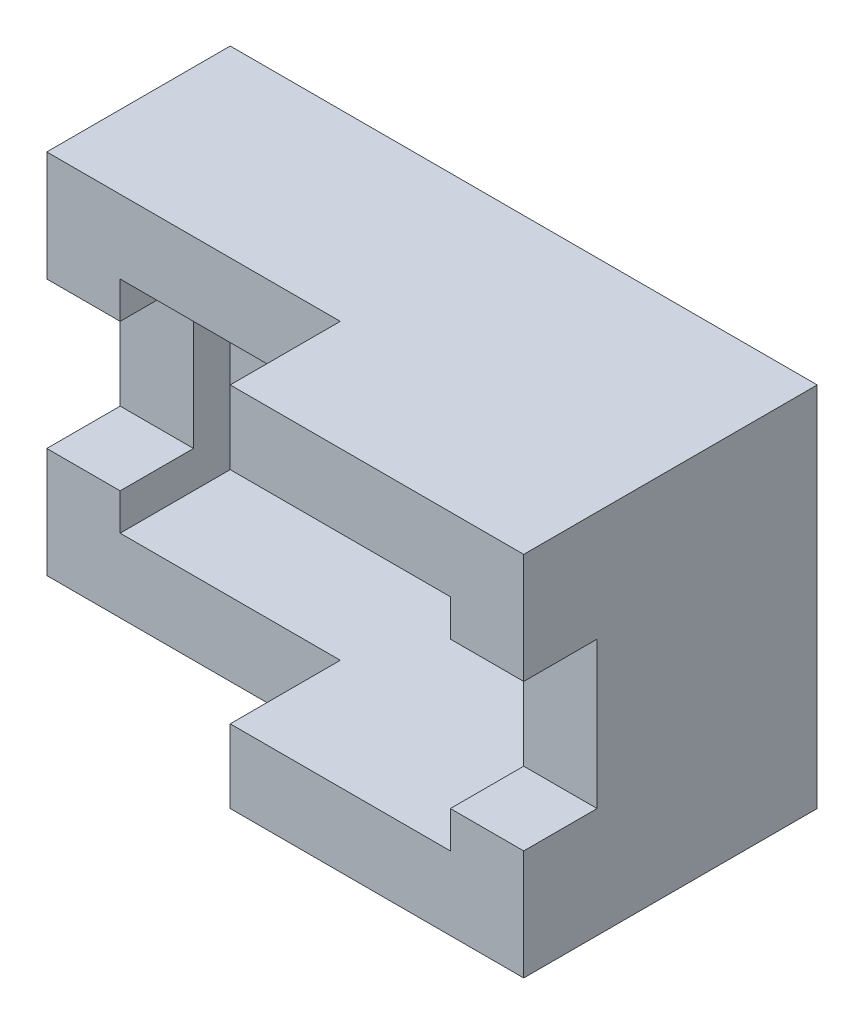
from build123d import *

# Parameters (mm, degrees)
SKETCH1_W           = 160
SKETCH1_H           = 100
BOSS_EXTRUDE1_DEPTH = 50
SKETCH2_W           = 20
SKETCH2_H           = 40
CUT_EXTRUDE1_DEPTH  = 20
SKETCH3_W           = 30
SKETCH3_H           = 20
CUT_EXTRUDE2_DEPTH  = 20
SKETCH4_W           = 120
SKETCH4_H           = 60
CUT_EXTRUDE3_DEPTH  = 30
BOSS_EXTRUDE2_DEPTH = 30
SKETCH8_W           = 30
SKETCH8_H           = 40
BOSS_EXTRUDE3_DEPTH = 20


with BuildPart() as part:
    # Sketch1 → Boss-Extrude1 (new body)
    with BuildSketch(Plane.XY):
        with Locations((80, 50)):
            Rectangle(SKETCH1_W, SKETCH1_H)
    extrude(amount=BOSS_EXTRUDE1_DEPTH)

    # Sketch2 → Cut-Extrude1 (cut)
    with BuildSketch(Plane.XY.offset(50)):
        with Locations((10, 50)):
            Rectangle(SKETCH2_W, SKETCH2_H)
        with Locations((150, 50)):
            Rectangle(SKETCH2_W, SKETCH2_H)
    extrude(amount=-CUT_EXTRUDE1_DEPTH, mode=Mode.SUBTRACT)

    # Sketch3 → Cut-Extrude2 (cut)
    with BuildSketch(Plane(origin=(0, 0, 0), x_dir=(-1, 0, 0), z_dir=(0, 0, -1))):
        with Locations((-55, 50)):
            Rectangle(SKETCH3_W, SKETCH3_H)
        with Locations((-105, 50)):
            Rectangle(SKETCH3_W, SKETCH3_H)
    extrude(amount=-CUT_EXTRUDE2_DEPTH, mode=Mode.SUBTRACT)

    # Sketch4 → Cut-Extrude3 (cut)
    with BuildSketch(Plane.XY.offset(50)):
        with Locations((80, 50)):
            Rectangle(SKETCH4_W, SKETCH4_H)
    extrude(amount=-CUT_EXTRUDE3_DEPTH, mode=Mode.SUBTRACT)

    # Sketch5 → Boss-Extrude2 (add)
    with BuildSketch(Plane.XY.offset(50)):
        Polygon((80, 100), (80, 80), (140, 80), (140, 70), (160, 70), (160, 100), align=None)
        Polygon((80, 0), (80, 20), (140, 20), (140, 30), (160, 30), (160, 0), align=None)
    extrude(amount=BOSS_EXTRUDE2_DEPTH)

    # Sketch8 → Boss-Extrude3 (add)
    with BuildSketch(Plane.ZY.offset(-140)):
        with Locations((45, 50)):
            Rectangle(SKETCH8_W, SKETCH8_H)
    extrude(amount=-BOSS_EXTRUDE3_DEPTH)


solid = part.part
